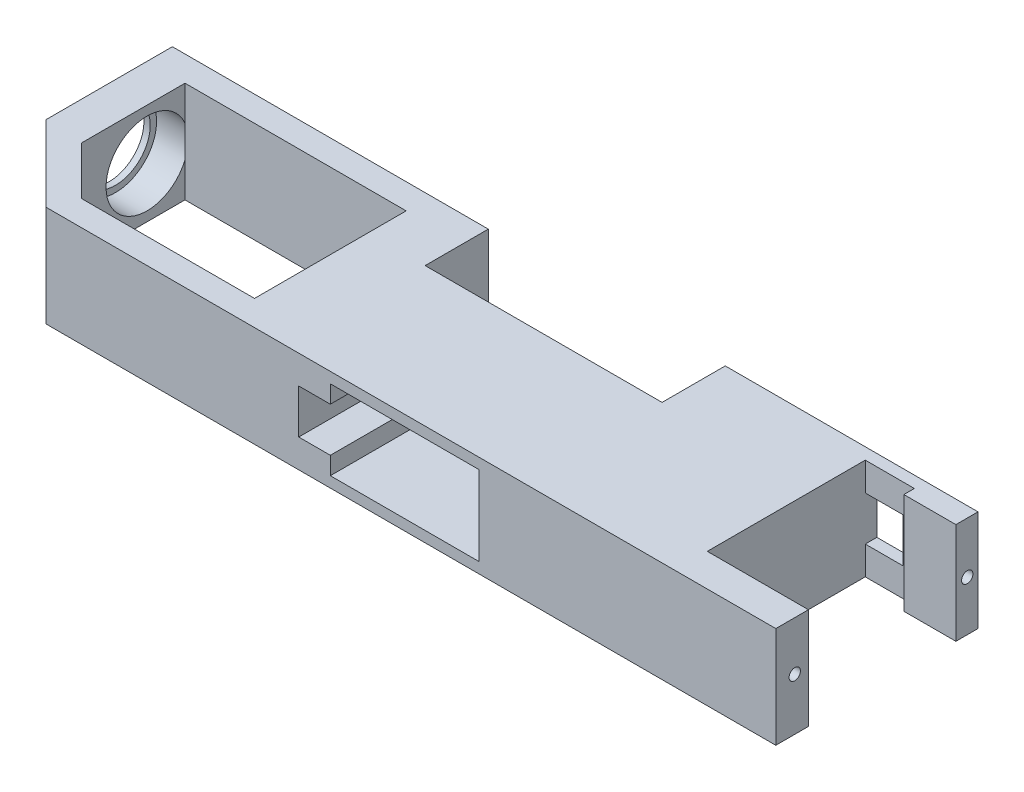
from build123d import *

# Parameters (mm, degrees)
BOSS_EXTRUDE1_DEPTH      = 8
BOSS_EXTRUDE1_DEPTH_BACK = 8
SKETCH2_R                = 5.5
CUT_EXTRUDE1_DEPTH       = 8
CUT_EXTRUDE2_DEPTH       = 16
SKETCH4_R                = 6.5
CUT_EXTRUDE3_DEPTH       = 5
SKETCH5_W                = 23.5
SKETCH5_H                = 12.6
CUT_EXTRUDE4_DEPTH       = 33
SKETCH6_R                = 0.9
CUT_EXTRUDE5_DEPTH       = 17
SKETCH7_W                = 6
SKETCH7_H                = 7
CUT_EXTRUDE6_DEPTH       = 7
SKETCH8_W                = 5
SKETCH8_H                = 7
CUT_EXTRUDE7_DEPTH       = 10
SKETCH9_R                = 0.9
CUT_EXTRUDE8_DEPTH       = 7
SKETCH10_W               = 37.5
SKETCH10_H               = 16
CUT_EXTRUDE9_DEPTH       = 10


with BuildPart() as part:
    # Sketch1 → Boss-Extrude1 (new body, two sides)
    with BuildSketch(Plane(origin=(0, 0, 0), x_dir=(1, 0, 0), z_dir=(0, 1, 0))) as boss_extrude1_sk:
        Polygon((64, -16.835969506), (47.993540801, -16.835969506), (47.993540801, 8.164030494), (55.763890835, 8.164030494), (55.763890835, 6.5), (64, 6.5), (64, 10), (-63.5, 10), (-63.5, -10), (-51.5, -22), (64, -22), align=None)
    extrude(amount=BOSS_EXTRUDE1_DEPTH)
    extrude(boss_extrude1_sk.sketch, amount=-BOSS_EXTRUDE1_DEPTH_BACK)

    # Sketch2 → Cut-Extrude1 (cut)
    with BuildSketch(Plane.ZY.offset(63.5)):
        Circle(SKETCH2_R)
    extrude(amount=-CUT_EXTRUDE1_DEPTH, mode=Mode.SUBTRACT)

    # Sketch3 → Cut-Extrude2 (cut)
    with BuildSketch(Plane(origin=(0, 8, 0), x_dir=(1, 0, 0), z_dir=(0, 1, 0))):
        Polygon((-57.5, 6), (-22.5, 6), (-22.5, -18), (-49.843145751, -18), (-57.5, -10.343145751), align=None)
    extrude(amount=-CUT_EXTRUDE2_DEPTH, mode=Mode.SUBTRACT)

    # Sketch4 → Cut-Extrude3 (cut)
    with BuildSketch(Plane(origin=(-57.5, 0, 0), x_dir=(0, 0, -1), z_dir=(1, 0, 0))):
        Circle(SKETCH4_R)
    extrude(amount=-CUT_EXTRUDE3_DEPTH, mode=Mode.SUBTRACT)

    # Sketch5 → Cut-Extrude4 (cut, through all)
    with BuildSketch(Plane(origin=(0, 0, -10), x_dir=(-1, 0, 0), z_dir=(0, 0, -1))):
        with Locations((-5.25, 0)):
            Rectangle(SKETCH5_W, SKETCH5_H)
    extrude(amount=-CUT_EXTRUDE4_DEPTH, mode=Mode.SUBTRACT)

    # Sketch6 → Cut-Extrude5 (cut)
    with BuildSketch(Plane(origin=(0, 0, -10), x_dir=(-1, 0, 0), z_dir=(0, 0, -1))):
        with Locations((8.3, 0)):
            Circle(SKETCH6_R)
        with Locations((-19, 0)):
            Circle(SKETCH6_R)
    extrude(amount=-CUT_EXTRUDE5_DEPTH, mode=Mode.SUBTRACT)

    # Sketch7 → Cut-Extrude6 (cut)
    with BuildSketch(Plane(origin=(0, 0, -10), x_dir=(-1, 0, 0), z_dir=(0, 0, -1))):
        with Locations((-50.993540801, 0)):
            Rectangle(SKETCH7_W, SKETCH7_H)
    extrude(amount=-CUT_EXTRUDE6_DEPTH, mode=Mode.SUBTRACT)

    # Sketch8 → Cut-Extrude7 (cut)
    with BuildSketch(Plane.XY.offset(22)):
        with Locations((-9, 0)):
            Rectangle(SKETCH8_W, SKETCH8_H)
    extrude(amount=-CUT_EXTRUDE7_DEPTH, mode=Mode.SUBTRACT)

    # Sketch9 → Cut-Extrude8 (cut)
    with BuildSketch(Plane(origin=(64, 0, 0), x_dir=(0, 0, -1), z_dir=(1, 0, 0))):
        with Locations((-18.998394534, 0.246992196)):
            Circle(SKETCH9_R)
        with Locations((8.299298665, -0.107896591)):
            Circle(SKETCH9_R)
    extrude(amount=-CUT_EXTRUDE8_DEPTH, mode=Mode.SUBTRACT)

    # Sketch10 → Cut-Extrude9 (cut)
    with BuildSketch(Plane(origin=(0, 0, -10), x_dir=(-1, 0, 0), z_dir=(0, 0, -1))):
        with Locations((-5.25, 0)):
            Rectangle(SKETCH10_W, SKETCH10_H)
    extrude(amount=-CUT_EXTRUDE9_DEPTH, mode=Mode.SUBTRACT)


solid = part.part
